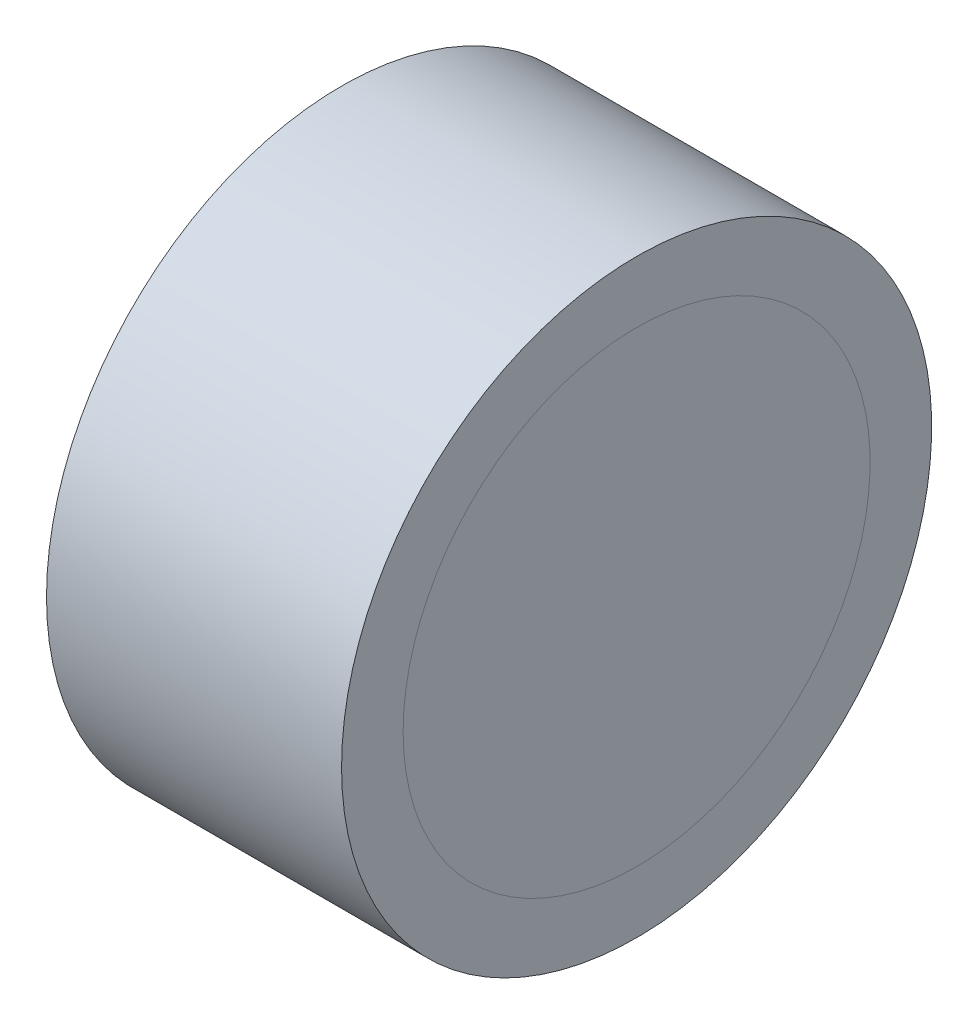
from build123d import *


with BuildPart() as part:
    # Sketch 1 → Revolve 1 (revolve)
    with BuildSketch(Plane.XY, mode=Mode.PRIVATE) as revolve_1_sk:
        Polygon((234.114519085, 114.575695895), (227.764519085, 114.575695895), (227.764519085, 113.250695895), (228.764519085, 113.250695895), (228.764519085, 112.275695895), (233.114519085, 112.275695895), (233.114519085, 113.250695895), (234.114519085, 113.250695895), align=None)
    revolve(revolve_1_sk.sketch.rotate(Axis((219.902332256, 108.225695895, 0), (1, 0, 0)), 90), axis=Axis((219.902332256, 108.225695895, 0), (1, 0, 0)))  # turned: the seam where the file's is


with BuildPart() as body_2:
    # Sketch 1_4 one side → Revolve 2 (revolve)
    with BuildSketch(Plane.XY, mode=Mode.PRIVATE) as revolve_2_sk:
        Polygon((228.764519085, 112.275695895), (228.764519085, 113.250695895), (227.764519085, 113.250695895), (227.764519085, 108.225695895), (228.764519085, 108.225695895), align=None)
    revolve(revolve_2_sk.sketch.rotate(Axis((219.902332256, 108.225695895, 0), (1, 0, 0)), 90), axis=Axis((219.902332256, 108.225695895, 0), (1, 0, 0)))  # turned: the seam where the file's is


with BuildPart() as body_3:
    # Sketch 1_5 one side → Revolve 3 (revolve)
    with BuildSketch(Plane.XY, mode=Mode.PRIVATE) as revolve_3_sk:
        Polygon((233.114519085, 108.225695895), (234.114519085, 108.225695895), (234.114519085, 113.250695895), (233.114519085, 113.250695895), (233.114519085, 112.275695895), align=None)
    revolve(revolve_3_sk.sketch.rotate(Axis((219.902332256, 108.225695895, 0), (1, 0, 0)), 90), axis=Axis((219.902332256, 108.225695895, 0), (1, 0, 0)))  # turned: the seam where the file's is


solid = Compound([part.part, body_2.part, body_3.part])
